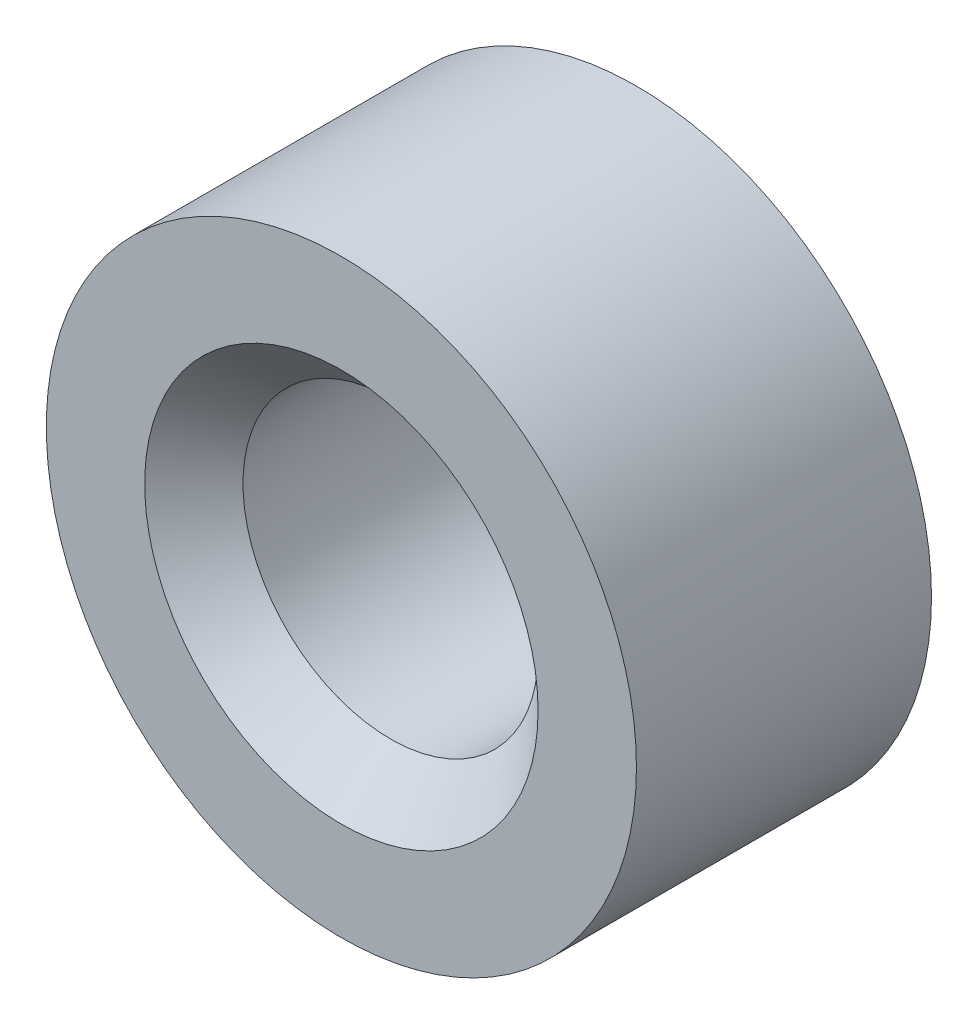
from build123d import *

# Parameters (mm, degrees)
SCHIZZO1_R                   = 3
SCHIZZO1_R_2                 = 1.5
ESTRUSIONE_ESTRUSIONE1_DEPTH = 3
SMUSSO1_SIZE                 = 0.5
CHAMFER1_SIZE                = 0.5


with BuildPart() as part:
    # Schizzo1 → Estrusione-Estrusione1 (new body)
    with BuildSketch(Plane.XY):
        Circle(SCHIZZO1_R)
        Circle(SCHIZZO1_R_2, mode=Mode.SUBTRACT)
    extrude(amount=ESTRUSIONE_ESTRUSIONE1_DEPTH)

    # Smusso1
    smusso1_edges = [part.edges().sort_by_distance(p)[0] for p in [
        (-1.5, 0, 3),
    ]]
    chamfer(smusso1_edges, length=SMUSSO1_SIZE)

    # Chamfer1
    chamfer1_edges = [part.edges().sort_by_distance(p)[0] for p in [
        (-1.5, 0, 0),
    ]]
    chamfer(chamfer1_edges, length=CHAMFER1_SIZE)


solid = part.part
